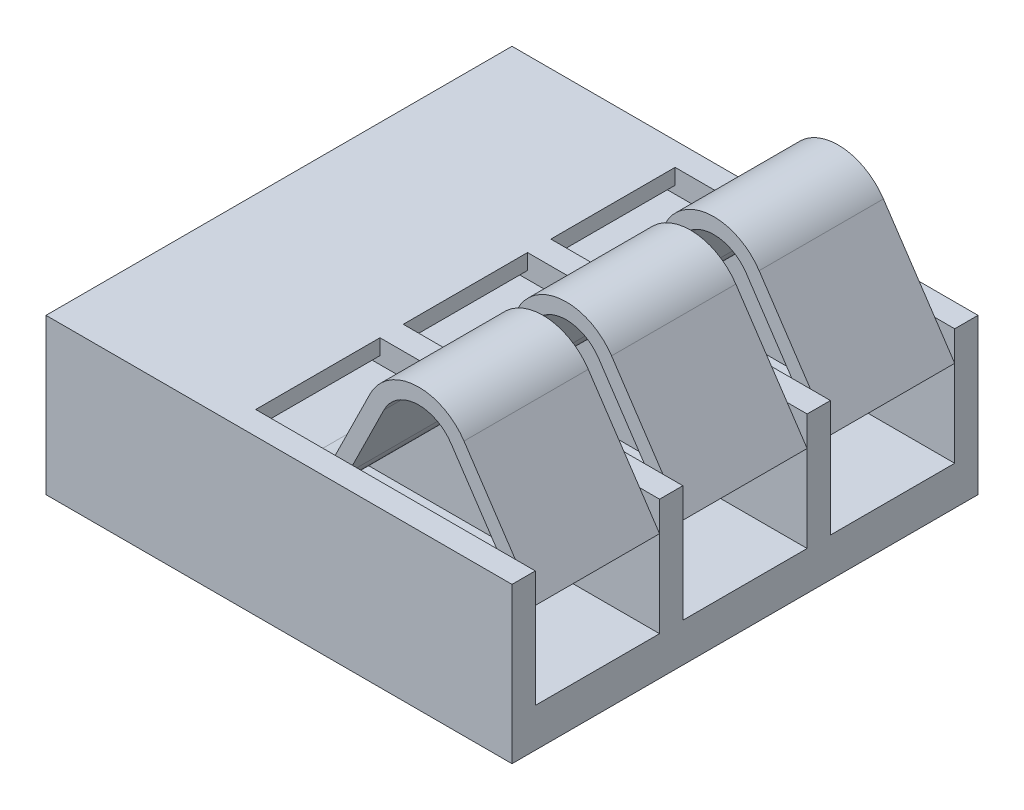
from build123d import *

# Parameters (mm, degrees)
BOSS_EXTRUDE1_DEPTH = 6
BOSS_EXTRUDE2_START = 0.3
BOSS_EXTRUDE2_DEPTH = 1.6
SKETCH1_3_W         = 5
SKETCH1_3_H         = 1
BOSS_EXTRUDE3_DEPTH = 0.3
BOSS_EXTRUDE4_START = 1.9
SKETCH1_5_W         = 5
SKETCH1_5_H         = 1
BOSS_EXTRUDE4_DEPTH = 0.3
BOSS_EXTRUDE5_START = 2.2
BOSS_EXTRUDE5_DEPTH = 1.6
BOSS_EXTRUDE6_START = 3.8
SKETCH1_6_W         = 5
SKETCH1_6_H         = 1
BOSS_EXTRUDE6_DEPTH = 0.3
BOSS_EXTRUDE7_START = 4.1
BOSS_EXTRUDE7_DEPTH = 1.6
BOSS_EXTRUDE8_START = 5.7
SKETCH1_7_W         = 5
SKETCH1_7_H         = 1
BOSS_EXTRUDE8_DEPTH = 0.3
SKETCH3_W           = 2.4
SKETCH3_H           = 6
BOSS_EXTRUDE9_DEPTH = 0.2


with BuildPart() as part:
    # Sketch1 → Boss-Extrude1 (new body)
    with BuildSketch(Plane.XY):
        Polygon((5.5, 0.5), (0.5, 0.5), (0.5, 1.5), (0.5, 2), (0, 2), (0, 0), (6, 0), (6, 0.5), align=None)
    extrude(amount=BOSS_EXTRUDE1_DEPTH)

    # Sketch2 → Boss-Extrude2 (add)
    with BuildSketch(Plane.XY.offset(BOSS_EXTRUDE2_START)):
        with BuildLine():
            Line((5.833702875, 1.503863094), (6, 1.614972348))
            Line((6, 1.614972348), (5.082039937, 2.988882388))
            ThreePointArc((5.082039937, 2.988882388), (4.454237941, 3.298502565), (3.872198004, 2.909620177))
            Line((3.872198004, 2.909620177), (3.413156013, 1.97884273))
            ThreePointArc((3.413156013, 1.97884273), (3.228753823, 1.775395104), (2.964726016, 1.7))
            Line((2.964726016, 1.7), (1.4, 1.7))
            ThreePointArc((1.4, 1.7), (0.905025253, 1.494974747), (0.7, 1))
            Line((0.7, 1), (0.7, 0.5))
            Line((0.7, 0.5), (0.9, 0.5))
            Line((0.9, 0.5), (0.9, 1))
            ThreePointArc((0.9, 1), (1.046446609, 1.353553391), (1.4, 1.5))
            Line((1.4, 1.5), (2.964726016, 1.5))
            ThreePointArc((2.964726016, 1.5), (3.334364945, 1.605553146), (3.592528012, 1.890379823))
            Line((3.592528012, 1.890379823), (4.051570003, 2.82115727))
            ThreePointArc((4.051570003, 2.82115727), (4.467312815, 3.098930404), (4.915742812, 2.877773134))
            Line((4.915742812, 2.877773134), (5.833702875, 1.503863094))
        make_face()
    extrude(amount=BOSS_EXTRUDE2_DEPTH)

    # Sketch1_3 → Boss-Extrude3 (add)
    with BuildSketch(Plane.XY):
        with Locations((3, 1)):
            Rectangle(SKETCH1_3_W, SKETCH1_3_H)
        Polygon((0.5, 2), (0.5, 1.5), (5.5, 1.5), (5.5, 0.5), (6, 0.5), (6, 2), align=None)
    extrude(amount=BOSS_EXTRUDE3_DEPTH)

    # Sketch1_5 → Boss-Extrude4 (add)
    with BuildSketch(Plane.XY.offset(BOSS_EXTRUDE4_START)):
        Polygon((0.5, 2), (0.5, 1.5), (5.5, 1.5), (5.5, 0.5), (6, 0.5), (6, 2), align=None)
        with Locations((3, 1)):
            Rectangle(SKETCH1_5_W, SKETCH1_5_H)
    extrude(amount=BOSS_EXTRUDE4_DEPTH)

    # Sketch2_3 → Boss-Extrude5 (add)
    with BuildSketch(Plane.XY.offset(BOSS_EXTRUDE5_START)):
        with BuildLine():
            Line((5.833702875, 1.503863094), (6, 1.614972348))
            Line((6, 1.614972348), (5.082039937, 2.988882388))
            ThreePointArc((5.082039937, 2.988882388), (4.454237941, 3.298502565), (3.872198004, 2.909620177))
            Line((3.872198004, 2.909620177), (3.413156013, 1.97884273))
            ThreePointArc((3.413156013, 1.97884273), (3.228753823, 1.775395104), (2.964726016, 1.7))
            Line((2.964726016, 1.7), (1.4, 1.7))
            ThreePointArc((1.4, 1.7), (0.905025253, 1.494974747), (0.7, 1))
            Line((0.7, 1), (0.7, 0.5))
            Line((0.7, 0.5), (0.9, 0.5))
            Line((0.9, 0.5), (0.9, 1))
            ThreePointArc((0.9, 1), (1.046446609, 1.353553391), (1.4, 1.5))
            Line((1.4, 1.5), (2.964726016, 1.5))
            ThreePointArc((2.964726016, 1.5), (3.334364945, 1.605553146), (3.592528012, 1.890379823))
            Line((3.592528012, 1.890379823), (4.051570003, 2.82115727))
            ThreePointArc((4.051570003, 2.82115727), (4.467312815, 3.098930404), (4.915742812, 2.877773134))
            Line((4.915742812, 2.877773134), (5.833702875, 1.503863094))
        make_face()
    extrude(amount=BOSS_EXTRUDE5_DEPTH)

    # Sketch1_6 → Boss-Extrude6 (add)
    with BuildSketch(Plane.XY.offset(BOSS_EXTRUDE6_START)):
        with Locations((3, 1)):
            Rectangle(SKETCH1_6_W, SKETCH1_6_H)
        Polygon((0.5, 2), (0.5, 1.5), (5.5, 1.5), (5.5, 0.5), (6, 0.5), (6, 2), align=None)
    extrude(amount=BOSS_EXTRUDE6_DEPTH)

    # Sketch2_4 → Boss-Extrude7 (add)
    with BuildSketch(Plane.XY.offset(BOSS_EXTRUDE7_START)):
        with BuildLine():
            Line((5.833702875, 1.503863094), (6, 1.614972348))
            Line((6, 1.614972348), (5.082039937, 2.988882388))
            ThreePointArc((5.082039937, 2.988882388), (4.454237941, 3.298502565), (3.872198004, 2.909620177))
            Line((3.872198004, 2.909620177), (3.413156013, 1.97884273))
            ThreePointArc((3.413156013, 1.97884273), (3.228753823, 1.775395104), (2.964726016, 1.7))
            Line((2.964726016, 1.7), (1.4, 1.7))
            ThreePointArc((1.4, 1.7), (0.905025253, 1.494974747), (0.7, 1))
            Line((0.7, 1), (0.7, 0.5))
            Line((0.7, 0.5), (0.9, 0.5))
            Line((0.9, 0.5), (0.9, 1))
            ThreePointArc((0.9, 1), (1.046446609, 1.353553391), (1.4, 1.5))
            Line((1.4, 1.5), (2.964726016, 1.5))
            ThreePointArc((2.964726016, 1.5), (3.334364945, 1.605553146), (3.592528012, 1.890379823))
            Line((3.592528012, 1.890379823), (4.051570003, 2.82115727))
            ThreePointArc((4.051570003, 2.82115727), (4.467312815, 3.098930404), (4.915742812, 2.877773134))
            Line((4.915742812, 2.877773134), (5.833702875, 1.503863094))
        make_face()
    extrude(amount=BOSS_EXTRUDE7_DEPTH)

    # Sketch1_7 → Boss-Extrude8 (add)
    with BuildSketch(Plane.XY.offset(BOSS_EXTRUDE8_START)):
        Polygon((0.5, 2), (0.5, 1.5), (5.5, 1.5), (5.5, 0.5), (6, 0.5), (6, 2), align=None)
        with Locations((3, 1)):
            Rectangle(SKETCH1_7_W, SKETCH1_7_H)
    extrude(amount=BOSS_EXTRUDE8_DEPTH)

    # Sketch3 → Boss-Extrude9 (add)
    with BuildSketch(Plane(origin=(0, 2, 0), x_dir=(1, 0, 0), z_dir=(0, 1, 0))):
        with Locations((1.2, -3)):
            Rectangle(SKETCH3_W, SKETCH3_H)
    extrude(amount=-BOSS_EXTRUDE9_DEPTH)


solid = part.part
